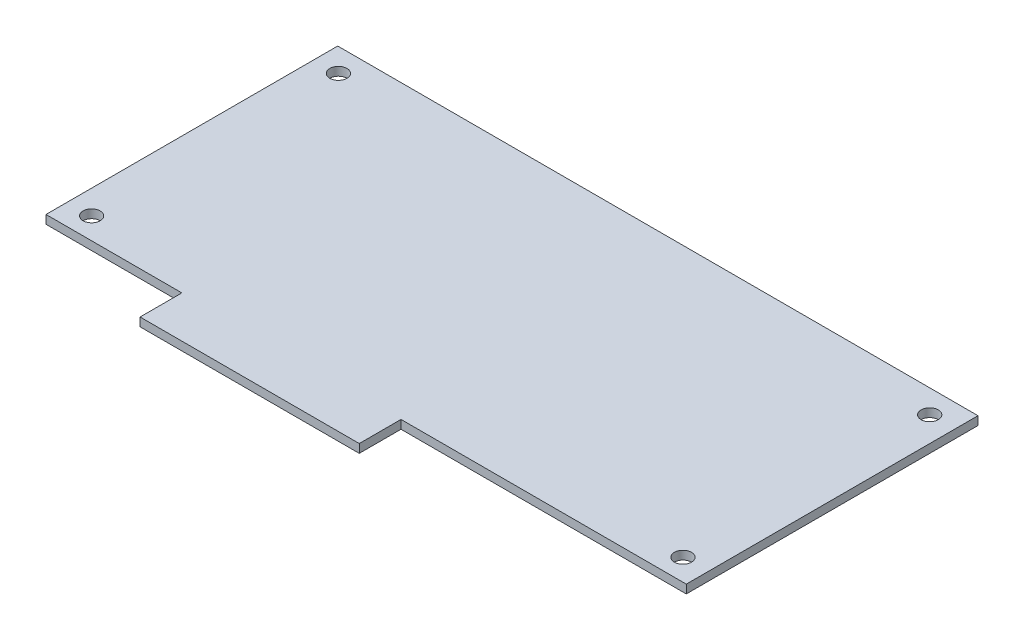
from build123d import *

# Parameters (mm, degrees)
BOSS_EXTRUDE1_DEPTH       = 1.6256
F_4_CLEARANCE_HOLE1_D     = 3.2639
F_4_CLEARANCE_HOLE1_DEPTH = 56.388
F_4_CLEARANCE_HOLE1_TIP   = 0.980574487


with BuildPart() as part:
    # Sketch1 → Boss-Extrude1 (new body)
    with BuildSketch(Plane(origin=(0, 0, 0), x_dir=(1, 0, 0), z_dir=(0, 1, 0))):
        Polygon((60.96, 31.75), (19.558, 31.75), (-17.272, 31.75), (-60.96, 31.75), (-60.96, -23.7998), (-35.09199383, -23.7998), (-35.09199383, -31.75), (6.64020617, -31.75), (6.64020617, -23.7998), (60.96, -23.7998), align=None)
    extrude(amount=BOSS_EXTRUDE1_DEPTH)

    # #4 Clearance Hole1
    with Locations(Plane(origin=(-46.701329526, 0, 29.554902493), x_dir=(-1, 0, 0), z_dir=(0, -1, 0))):
        with Locations((-102.911529526, 9.869902493), (-102.911529526, 56.859902493), (9.686670474, 56.859902493), (9.686670474, 9.869902493)):
            Hole(F_4_CLEARANCE_HOLE1_D / 2, depth=F_4_CLEARANCE_HOLE1_DEPTH)
            with Locations((0, 0, -(F_4_CLEARANCE_HOLE1_DEPTH + F_4_CLEARANCE_HOLE1_TIP / 2))):  # 118° drill point
                Cone(0, F_4_CLEARANCE_HOLE1_D / 2, F_4_CLEARANCE_HOLE1_TIP, mode=Mode.SUBTRACT)


solid = part.part
